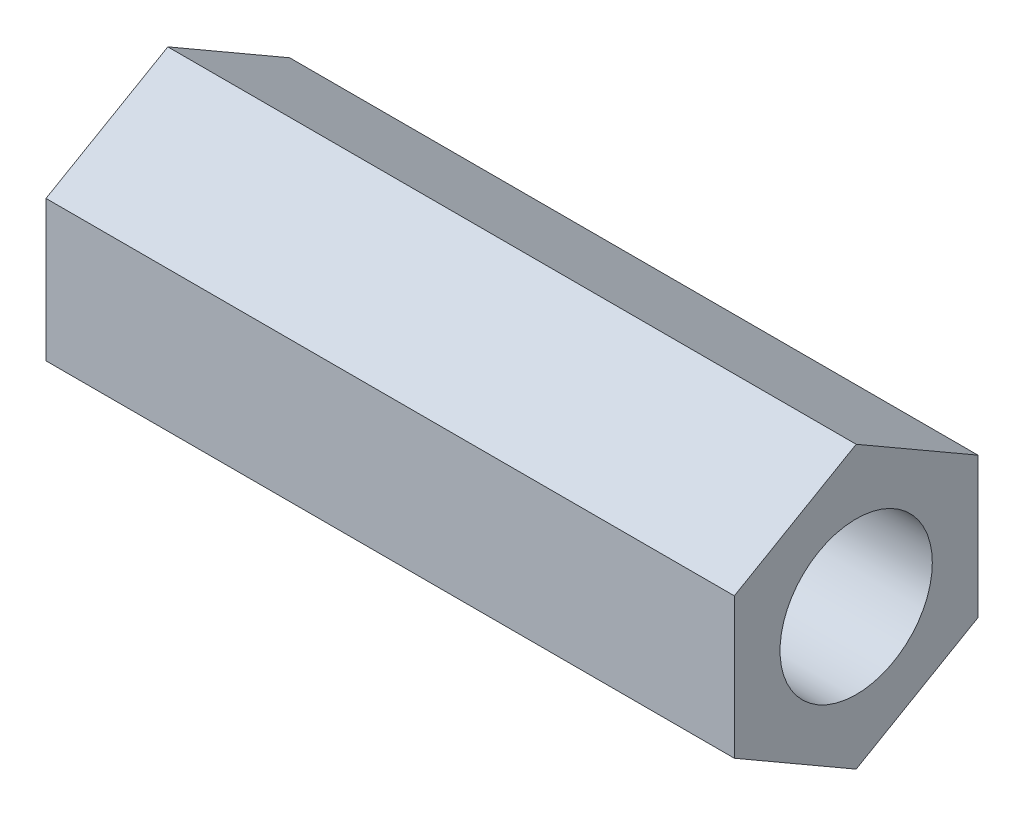
from build123d import *

# Parameters (mm, degrees)
SKETCH1_R           = 2.5
BOSS_EXTRUDE1_DEPTH = 22.6


with BuildPart() as part:
    # Sketch1 → Boss-Extrude1 (new body)
    with BuildSketch(Plane(origin=(0, 0, 0), x_dir=(0, 0, -1), z_dir=(1, 0, 0))):
        Polygon((0, 4.618802154), (-4, 2.309401077), (-4, -2.309401077), (0, -4.618802154), (4, -2.309401077), (4, 2.309401077), align=None)
        Circle(SKETCH1_R, mode=Mode.SUBTRACT)
    extrude(amount=BOSS_EXTRUDE1_DEPTH)


solid = part.part
